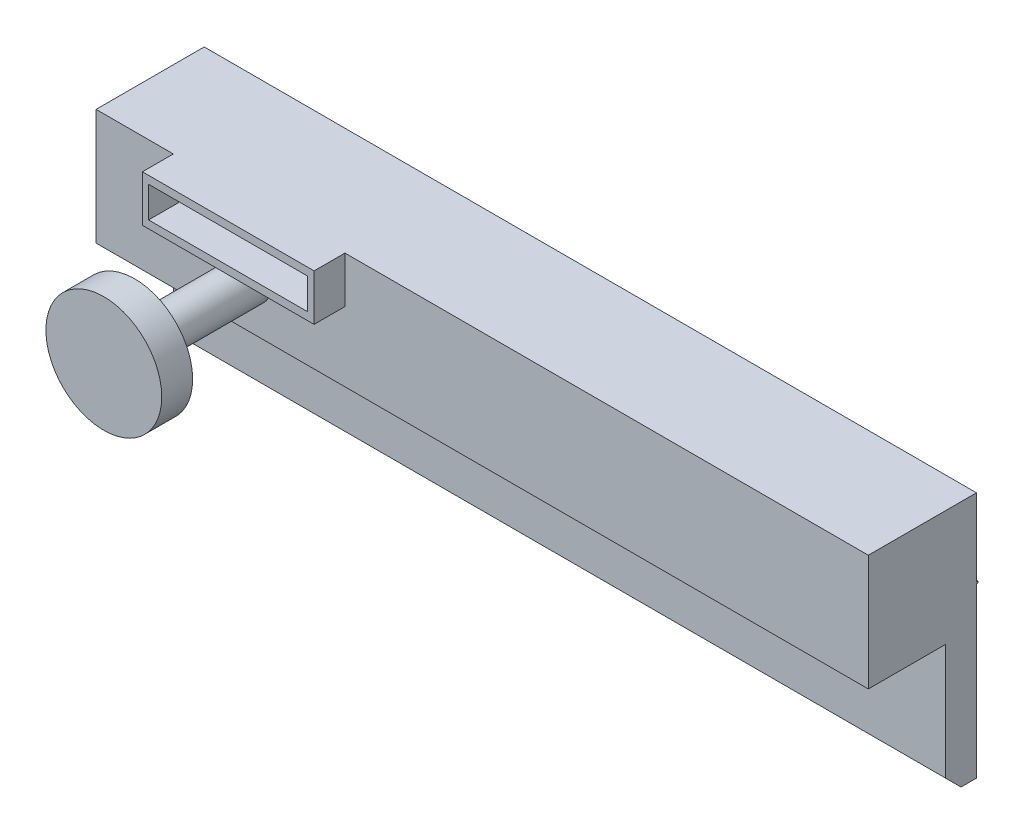
from build123d import *

# Parameters (mm, degrees)
SKETCH1_W            = 127
SKETCH1_H            = 40.64
BOSS_EXTRUDE1_DEPTH  = 5.08
CHAMFER3_SIZE        = 2.54
SKETCH6_W            = 127
SKETCH6_H            = 19.05
BOSS_EXTRUDE4_DEPTH  = 12.7
SKETCH14_R           = 3.175
BOSS_EXTRUDE9_DEPTH  = 19.05
SKETCH15_R           = 9.525
BOSS_EXTRUDE10_DEPTH = 5.08
SKETCH16_W           = 28.22730188
SKETCH16_H           = 7.62
BOSS_EXTRUDE11_DEPTH = 5.08
SKETCH17_W           = 26.13431135
SKETCH17_H           = 5.08
CUT_EXTRUDE4_DEPTH   = 5.08
SKETCH18_W           = 127
SKETCH18_H           = 0.254
BOSS_EXTRUDE12_DEPTH = 0.254


with BuildPart() as part:
    # Sketch1 → Boss-Extrude1 (new body)
    with BuildSketch(Plane.XY):
        with Locations((63.5, 20.32)):
            Rectangle(SKETCH1_W, SKETCH1_H)
    extrude(amount=BOSS_EXTRUDE1_DEPTH)

    # Chamfer3
    chamfer3_edges = [part.edges().sort_by_distance(p)[0] for p in [
        (63.5, 0, 5.08),
    ]]
    chamfer(chamfer3_edges, length=CHAMFER3_SIZE)

    # Sketch6 → Boss-Extrude4 (add)
    with BuildSketch(Plane.XY.offset(5.08)):
        with Locations((63.5, 31.115)):
            Rectangle(SKETCH6_W, SKETCH6_H)
    extrude(amount=BOSS_EXTRUDE4_DEPTH)

    # Sketch14 → Boss-Extrude9 (add)
    with BuildSketch(Plane.XY.offset(17.78)):
        with Locations((25.4, 29.21)):
            Circle(SKETCH14_R)
    extrude(amount=BOSS_EXTRUDE9_DEPTH)

    # Sketch15 → Boss-Extrude10 (add)
    with BuildSketch(Plane.XY.offset(36.83)):
        with Locations((25.4, 29.21)):
            Circle(SKETCH15_R)
    extrude(amount=BOSS_EXTRUDE10_DEPTH)

    # Sketch16 → Boss-Extrude11 (add)
    with BuildSketch(Plane.XY.offset(17.78)):
        with Locations((26.81365094, 36.83)):
            Rectangle(SKETCH16_W, SKETCH16_H)
    extrude(amount=BOSS_EXTRUDE11_DEPTH)

    # Sketch17 → Cut-Extrude4 (cut)
    with BuildSketch(Plane.XY.offset(22.86)):
        with Locations((26.783155675, 36.83)):
            Rectangle(SKETCH17_W, SKETCH17_H)
    extrude(amount=-CUT_EXTRUDE4_DEPTH, mode=Mode.SUBTRACT)

    # Sketch18 → Boss-Extrude12 (add)
    with BuildSketch(Plane(origin=(0, 0, 0), x_dir=(-1, 0, 0), z_dir=(0, 0, -1))):
        with Locations((-63.5, 27.813)):
            Rectangle(SKETCH18_W, SKETCH18_H)
    extrude(amount=BOSS_EXTRUDE12_DEPTH)


solid = part.part
